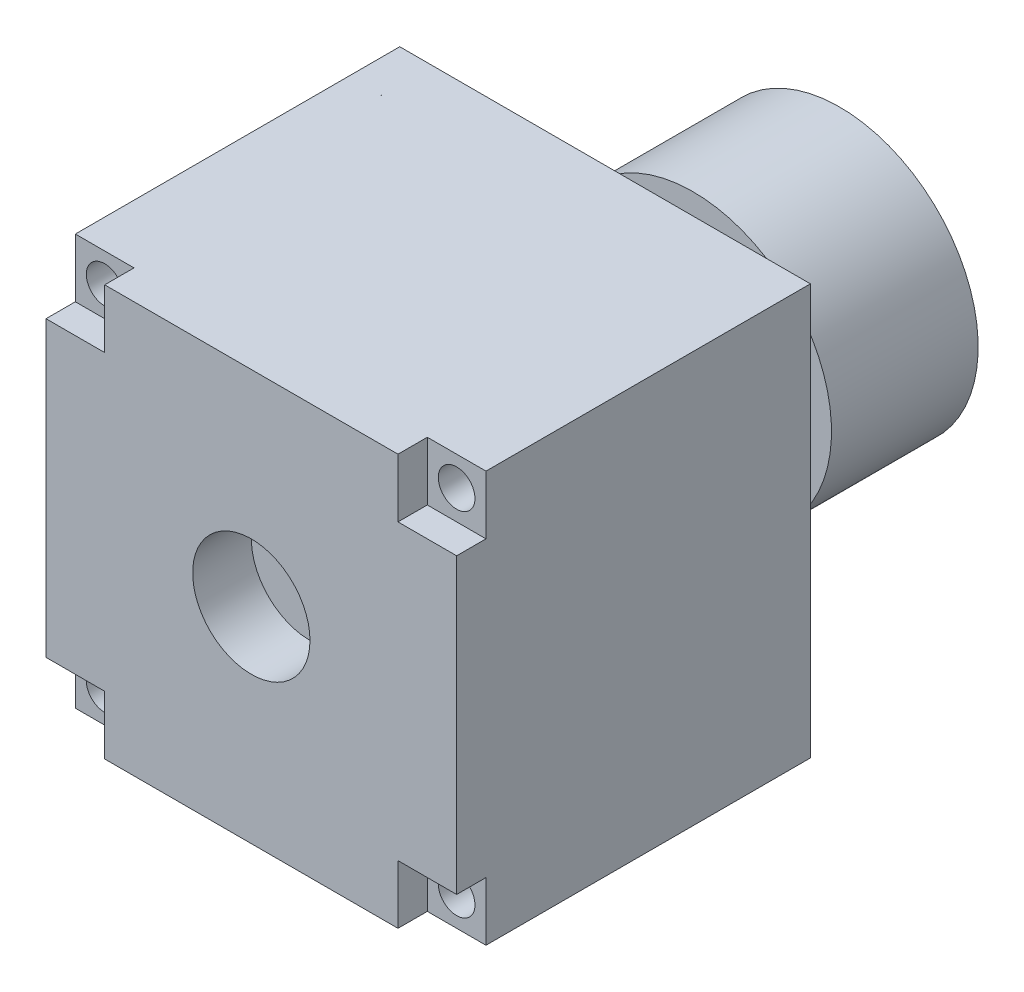
from build123d import *

# Parameters (mm, degrees)
SKETCH_1_W               = 28
SKETCH_1_H               = 28
EXTRUDE_1_DEPTH          = 24.12
SKETCH_2_R               = 4
SKETCH_2_W               = 4
SKETCH_2_H               = 4
CUT_EXTRUDE_1_DEPTH      = 2
SKETCH_3_R               = 4
CUT_EXTRUDE_2_DEPTH      = 2
HOLE_WIZARD_M3_2_D       = 2.5
HOLE_WIZARD_M3_2_DEPTH   = 22.121
PATTERN_CIRCULAR_4_COUNT = 4
PATTERN_CIRCULAR_5_COUNT = 4
SKETCH_7_R               = 2
EXTRUDE_2_DEPTH          = 6
SKETCH_8_R               = 9.44
SKETCH_8_R_2             = 4
EXTRUDE_3_DEPTH          = 10


with BuildPart() as part:
    # 草图1 → 凸台-拉伸1 (new body)
    with BuildSketch(Plane.XY):
        Rectangle(SKETCH_1_W, SKETCH_1_H)
    extrude(amount=EXTRUDE_1_DEPTH)

    # 草图2 → 切除-拉伸1 (cut)
    with BuildSketch(Plane.XY.offset(24.12)):
        Circle(SKETCH_2_R)
        with Locations((-12, -12)):
            Rectangle(SKETCH_2_W, SKETCH_2_H)
    cut_extrude_1 = extrude(amount=-CUT_EXTRUDE_1_DEPTH, mode=Mode.SUBTRACT)

    # 草图3 → 切除-拉伸2 (cut)
    with BuildSketch(Plane.XY.offset(22.12)):
        Circle(SKETCH_3_R)
    extrude(amount=-CUT_EXTRUDE_2_DEPTH, mode=Mode.SUBTRACT)

    # M3 螺纹孔2
    with Locations(Plane(origin=(-12, -12, 22.12), x_dir=(1, 0, 0), z_dir=(0, 0, 1))):
        with Locations((0, 0)):
            hole_wizard_m3_2 = Hole(HOLE_WIZARD_M3_2_D / 2, depth=HOLE_WIZARD_M3_2_DEPTH)

    # 阵列(圆周)4: 切除-拉伸1 ×4 about axis
    pattern_circular_4_axis = Axis((0, 0, 0), (0, 0, 1))
    for i in range(1, PATTERN_CIRCULAR_4_COUNT):
        add(cut_extrude_1.rotate(pattern_circular_4_axis, i * 360 / PATTERN_CIRCULAR_4_COUNT), mode=Mode.SUBTRACT)

    # 阵列(圆周)5: M3 螺纹孔2 ×4 about axis
    pattern_circular_5_axis = Axis((0, 0, 0), (0, 0, 1))
    for i in range(1, PATTERN_CIRCULAR_5_COUNT):
        add(hole_wizard_m3_2.rotate(pattern_circular_5_axis, i * 360 / PATTERN_CIRCULAR_5_COUNT), mode=Mode.SUBTRACT)

    # 草图7 → 凸台-拉伸2 (add)
    with BuildSketch(Plane(origin=(0, 0, 0), x_dir=(-1, 0, 0), z_dir=(0, 0, -1))):
        Circle(SKETCH_7_R)
    extrude(amount=EXTRUDE_2_DEPTH)


with BuildPart() as body_2:
    # 草图8 → 凸台-拉伸3 (new body)
    with BuildSketch(Plane(origin=(0, 0, -6), x_dir=(-1, 0, 0), z_dir=(0, 0, -1))):
        Circle(SKETCH_8_R)
        Circle(SKETCH_8_R_2, mode=Mode.SUBTRACT)
    extrude(amount=EXTRUDE_3_DEPTH)


solid = Compound([part.part, body_2.part])
